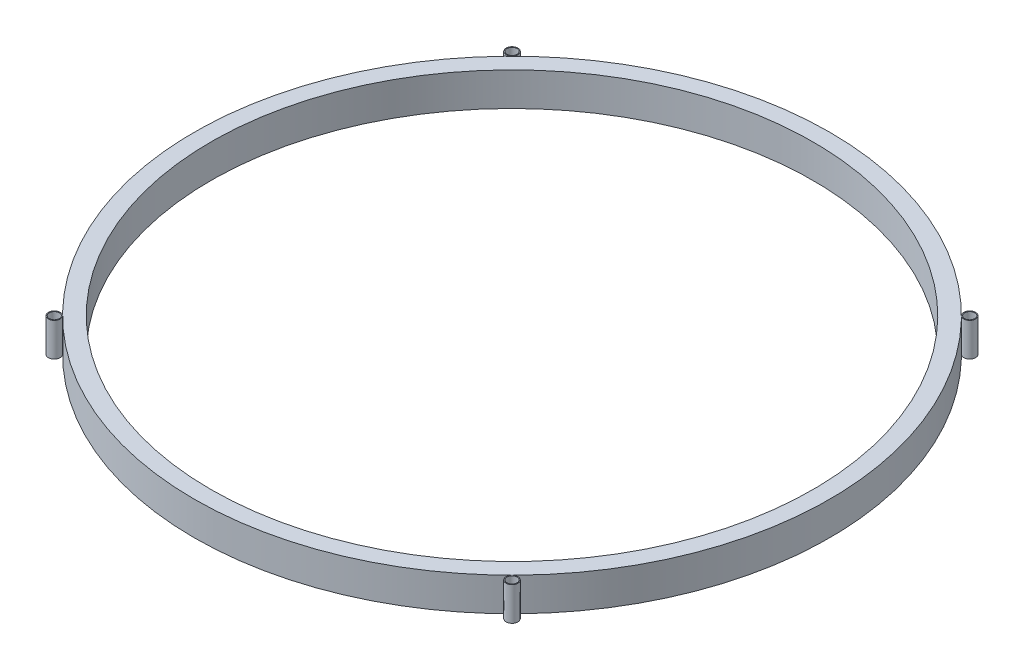
from build123d import *

# Parameters (mm, degrees)
SKETCH_1_R        = 95
SKETCH_1_R_2      = 90
EXTRUDE_2_DEPTH   = 10
SKETCH_1_R_3      = 1.75
SKETCH_1_R_4      = 1.5
EXTRUDE_2_2_DEPTH = 10
EXTRUDE_2_3_DEPTH = 10
EXTRUDE_2_4_DEPTH = 10
EXTRUDE_2_5_DEPTH = 10


with BuildPart() as part:
    # Эскиз1 → Бобышка-Вытянуть2 (new body)
    with BuildSketch(Plane(origin=(0, 0, 0), x_dir=(1, 0, 0), z_dir=(0, 1, 0))):
        Circle(SKETCH_1_R)
        Circle(SKETCH_1_R_2, mode=Mode.SUBTRACT)
    extrude(amount=EXTRUDE_2_DEPTH)


with BuildPart() as body_2:
    # Эскиз1 → Extrude 2 2 (new body)
    with BuildSketch(Plane(origin=(0, 0, 0), x_dir=(1, 0, 0), z_dir=(0, 1, 0))):
        with Locations((68.41258108, 68.41258108)):
            Circle(SKETCH_1_R_3)
        with Locations((68.41258108, 68.41258108)):
            Circle(SKETCH_1_R_4, mode=Mode.SUBTRACT)
    extrude(amount=EXTRUDE_2_2_DEPTH)


with BuildPart() as body_3:
    # Эскиз1 → Extrude 2 3 (new body)
    with BuildSketch(Plane(origin=(0, 0, 0), x_dir=(1, 0, 0), z_dir=(0, 1, 0))):
        with Locations((68.41258108, -68.41258108)):
            Circle(SKETCH_1_R_3)
        with Locations((68.41258108, -68.41258108)):
            Circle(SKETCH_1_R_4, mode=Mode.SUBTRACT)
    extrude(amount=EXTRUDE_2_3_DEPTH)


with BuildPart() as body_4:
    # Эскиз1 → Extrude 2 4 (new body)
    with BuildSketch(Plane(origin=(0, 0, 0), x_dir=(1, 0, 0), z_dir=(0, 1, 0))):
        with Locations((-68.41258108, -68.41258108)):
            Circle(SKETCH_1_R_3)
        with Locations((-68.41258108, -68.41258108)):
            Circle(SKETCH_1_R_4, mode=Mode.SUBTRACT)
    extrude(amount=EXTRUDE_2_4_DEPTH)


with BuildPart() as body_5:
    # Эскиз1 → Extrude 2 5 (new body)
    with BuildSketch(Plane(origin=(0, 0, 0), x_dir=(1, 0, 0), z_dir=(0, 1, 0))):
        with Locations((-68.41258108, 68.41258108)):
            Circle(SKETCH_1_R_3)
        with Locations((-68.41258108, 68.41258108)):
            Circle(SKETCH_1_R_4, mode=Mode.SUBTRACT)
    extrude(amount=EXTRUDE_2_5_DEPTH)


solid = Compound([part.part, body_2.part, body_3.part, body_4.part, body_5.part])
